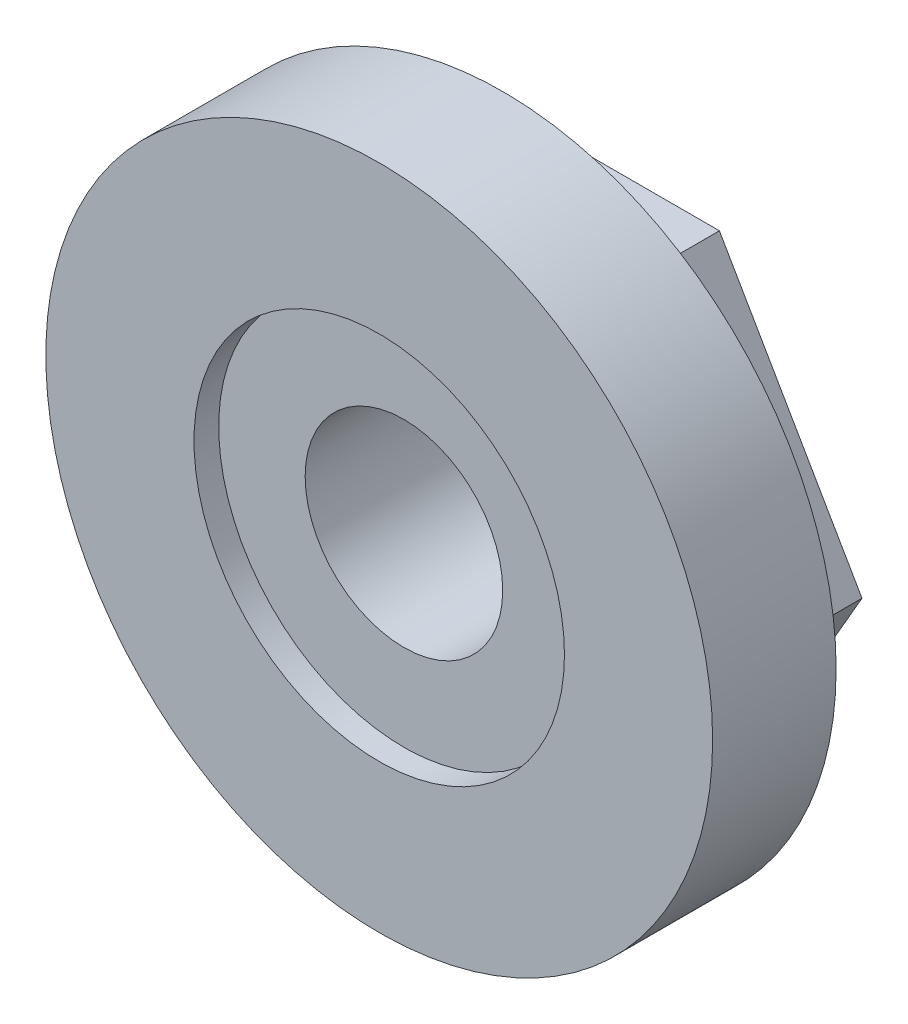
from build123d import *

# Parameters (mm, degrees)
BOSS_EXTRUDE1_DEPTH = 3
SKETCH2_R           = 13.5
BOSS_EXTRUDE2_DEPTH = 5
SKETCH3_R           = 7.5
CUT_EXTRUDE1_DEPTH  = 1
SKETCH4_R           = 4
CUT_EXTRUDE2_DEPTH  = 9


with BuildPart() as part:
    # Sketch1 → Boss-Extrude1 (new body)
    with BuildSketch(Plane.XY):
        Polygon((5.773502692, -10), (11.547005384, 0), (5.773502692, 10), (-5.773502692, 10), (-11.547005384, 0), (-5.773502692, -10), align=None)
    extrude(amount=BOSS_EXTRUDE1_DEPTH)

    # Sketch2 → Boss-Extrude2 (add)
    with BuildSketch(Plane.XY.offset(3)):
        Circle(SKETCH2_R)
    extrude(amount=BOSS_EXTRUDE2_DEPTH)

    # Sketch3 → Cut-Extrude1 (cut)
    with BuildSketch(Plane.XY.offset(8)):
        Circle(SKETCH3_R)
    extrude(amount=-CUT_EXTRUDE1_DEPTH, mode=Mode.SUBTRACT)

    # Sketch4 → Cut-Extrude2 (cut, through all)
    with BuildSketch(Plane(origin=(0, 0, 0), x_dir=(-1, 0, 0), z_dir=(0, 0, -1))):
        Circle(SKETCH4_R)
    extrude(amount=-CUT_EXTRUDE2_DEPTH, mode=Mode.SUBTRACT)


solid = part.part
